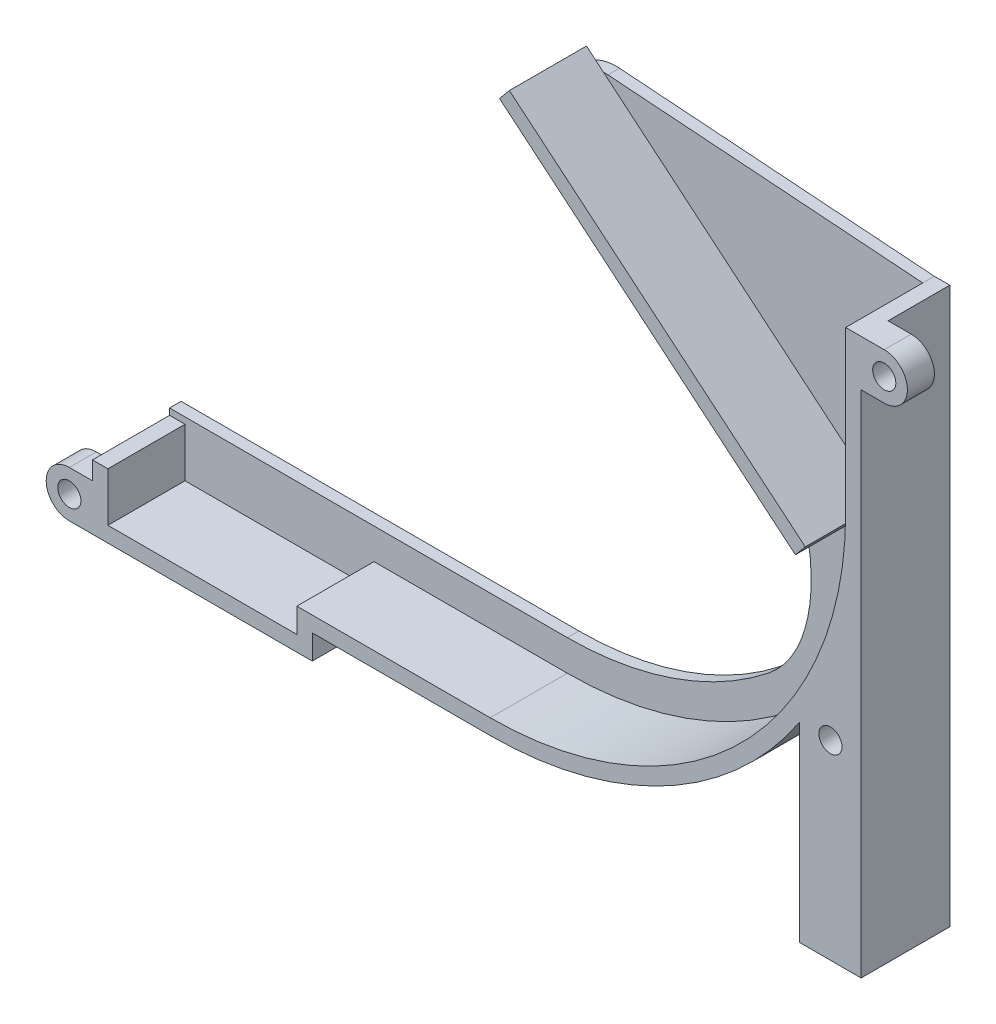
from build123d import *

# Parameters (mm, degrees)
BOSS_EXTRUDE1_DEPTH = 10
BOSS_EXTRUDE2_DEPTH = 1.5
BOSS_EXTRUDE4_DEPTH = 10
SKETCH4_R           = 1.5
BOSS_EXTRUDE3_DEPTH = 11.5
SKETCH5_R           = 1.5
SKETCH5_R_2         = 3
CUT_EXTRUDE1_DEPTH  = 8


with BuildPart() as part:
    # Sketch1 → Boss-Extrude1 (new body)
    with BuildSketch(Plane.XY):
        with BuildLine():
            Line((23.126155741, 11.486298975), (23.126155741, -9.296311409))
            ThreePointArc((23.126155741, -9.296311409), (9.625591469, -41.889556774), (-22.967653896, -55.390121046))
            Line((-22.967653896, -55.390121046), (-48.04069211, -55.390121046))
            Line((-48.04069211, -55.390121046), (-48.04069211, -58.565121046))
            Line((-48.04069211, -58.565121046), (-72.54069211, -58.565121046))
            Line((-72.54069211, -58.565121046), (-72.54069211, -52.215121046))
            Line((-72.54069211, -52.215121046), (-74.54069211, -52.215121046))
            Line((-74.54069211, -52.215121046), (-74.54069211, -60.565121046))
            Line((-74.54069211, -60.565121046), (-46.04069211, -60.565121046))
            Line((-46.04069211, -60.565121046), (-46.04069211, -57.390121046))
            Line((-46.04069211, -57.390121046), (-22.967653896, -57.390121046))
            ThreePointArc((-22.967653896, -57.390121046), (11.039805031, -43.303770336), (25.126155741, -9.296311409))
            Line((25.126155741, -9.296311409), (25.126155741, 11.486298975))
            Line((25.126155741, 11.486298975), (23.126155741, 11.486298975))
        make_face()
    extrude(amount=BOSS_EXTRUDE1_DEPTH)

    # Sketch2 → Boss-Extrude2 (add)
    with BuildSketch(Plane(origin=(0, 0, 0), x_dir=(-1, 0, 0), z_dir=(0, 0, -1))):
        with BuildLine():
            Line((-23.126155741, 11.486298975), (17.693603893, 14.436753165))
            ThreePointArc((17.693603893, 14.436753165), (23.933278885, 9.961444684), (20.661865311, 3.014518513))
            add(Edge.make_bspline(
                [(20.661865311, 3.014518513), (14.467019278, 0.125814366), (-11.141513341, -11.233209967), (-9.492969782, -37.302039453), (-3.109665986, -42.33964958)],
                knots=[0, 0, 0, 0, 0.582936219, 1, 1, 1, 1], degree=3))
            ThreePointArc((-3.109665986, -42.33964958), (9.166044877, -49.06318705), (22.967653896, -51.390121046))
            Line((22.967653896, -51.390121046), (52.04069211, -51.390121046))
            Line((52.04069211, -51.390121046), (74.54069211, -51.390121046))
            Line((74.54069211, -51.390121046), (74.54069211, -52.215121046))
            Line((74.54069211, -52.215121046), (74.54069211, -60.565121046))
            Line((74.54069211, -60.565121046), (46.04069211, -60.565121046))
            Line((46.04069211, -60.565121046), (46.04069211, -57.390121046))
            Line((46.04069211, -57.390121046), (22.967653896, -57.390121046))
            ThreePointArc((22.967653896, -57.390121046), (-11.039805031, -43.303770336), (-25.126155741, -9.296311409))
            Line((-25.126155741, -9.296311409), (-25.126155741, 11.486298975))
            Line((-25.126155741, 11.486298975), (-23.126155741, 11.486298975))
        make_face()
    extrude(amount=BOSS_EXTRUDE2_DEPTH)

    # Sketch6 → Boss-Extrude4 (add)
    with BuildSketch(Plane.XY):
        Polygon((-21.765334092, 14.753493125), (16.605109206, -17.304408883), (17.887425286, -15.769591151), (-20.483018011, 16.288310857), align=None)
    extrude(amount=BOSS_EXTRUDE4_DEPTH)

    # Sketch4 → Boss-Extrude3 (add)
    with BuildSketch(Plane(origin=(0, 0, -1.5), x_dir=(-1, 0, 0), z_dir=(0, 0, -1))):
        with BuildLine():
            Line((-25.126155741, -9.296311409), (-25.126155741, -60.565121046))
            Line((-25.126155741, -60.565121046), (-17.126155741, -60.565121046))
            Line((-17.126155741, -60.565121046), (-17.126155741, -35.857579341))
            ThreePointArc((-17.126155741, -35.857579341), (-23.082745525, -23.166251515), (-25.126155741, -9.296311409))
        make_face()
        with Locations((-21.147916143, -35.857579341)):
            Circle(SKETCH4_R, mode=Mode.SUBTRACT)
        with BuildLine():
            Line((-28.126155741, 11.486298975), (-25.126155741, 11.486298975))
            Line((-25.126155741, 11.486298975), (-25.126155741, 5.486298975))
            Line((-25.126155741, 5.486298975), (-28.126155741, 5.486298975))
            ThreePointArc((-28.126155741, 5.486298975), (-31.126155741, 8.486298975), (-28.126155741, 11.486298975))
        make_face()
        with Locations((-28.126155741, 8.486298975)):
            Circle(SKETCH4_R, mode=Mode.SUBTRACT)
        with BuildLine():
            Line((74.54069211, -60.565121046), (74.54069211, -54.565121046))
            Line((74.54069211, -54.565121046), (77.54069211, -54.565121046))
            ThreePointArc((77.54069211, -54.565121046), (80.54069211, -57.565121046), (77.54069211, -60.565121046))
            Line((77.54069211, -60.565121046), (74.54069211, -60.565121046))
        make_face()
        with Locations((77.54069211, -57.565121046)):
            Circle(SKETCH4_R, mode=Mode.SUBTRACT)
    extrude(amount=-BOSS_EXTRUDE3_DEPTH)

    # Sketch5 → Cut-Extrude1 (cut)
    with BuildSketch(Plane(origin=(0, 0, -1.5), x_dir=(-1, 0, 0), z_dir=(0, 0, -1))):
        with BuildLine():
            Line((77.54069211, -54.565121046), (74.54069211, -54.565121046))
            Line((74.54069211, -54.565121046), (74.54069211, -60.565121046))
            Line((74.54069211, -60.565121046), (77.54069211, -60.565121046))
            ThreePointArc((77.54069211, -60.565121046), (80.54069211, -57.565121046), (77.54069211, -54.565121046))
        make_face()
        with Locations((77.54069211, -57.565121046)):
            Circle(SKETCH5_R, mode=Mode.SUBTRACT)
        with Locations((-21.147916143, -35.857579341)):
            Circle(SKETCH5_R_2)
        with Locations((-21.147916143, -35.857579341)):
            Circle(SKETCH5_R, mode=Mode.SUBTRACT)
        with BuildLine():
            Line((-28.126155741, 5.486298975), (-25.126155741, 5.486298975))
            Line((-25.126155741, 5.486298975), (-25.126155741, 11.486298975))
            Line((-25.126155741, 11.486298975), (-28.126155741, 11.486298975))
            ThreePointArc((-28.126155741, 11.486298975), (-31.126155741, 8.486298975), (-28.126155741, 5.486298975))
        make_face()
        with Locations((-28.126155741, 8.486298975)):
            Circle(SKETCH5_R, mode=Mode.SUBTRACT)
    extrude(amount=-CUT_EXTRUDE1_DEPTH, mode=Mode.SUBTRACT)


solid = part.part
